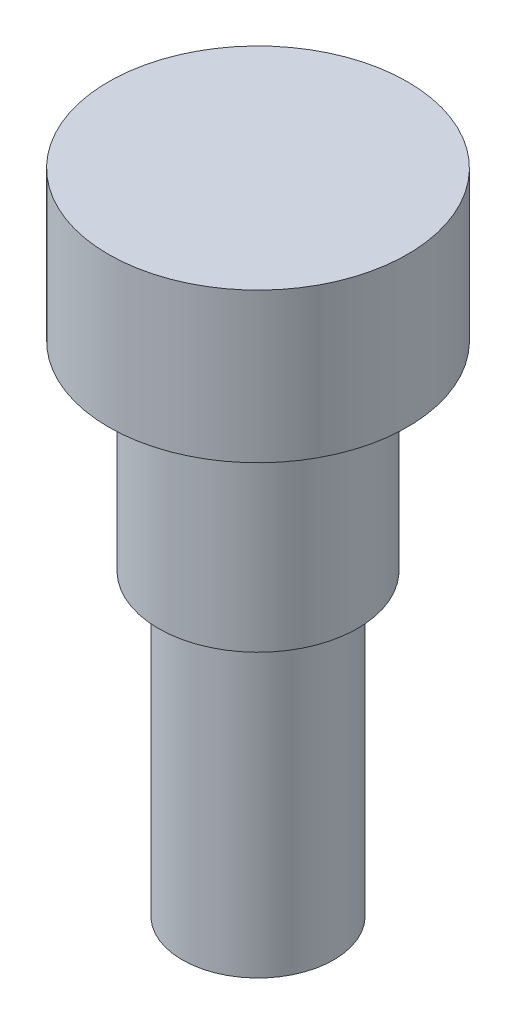
from build123d import *


with BuildPart() as part:
    # Sketch1 → Revolve1 (revolve)
    with BuildSketch(Plane.XY):
        Polygon((0, -9.525), (2.413, -9.525), (2.413, 0), (3.175, 0), (3.175, 6.35), (4.7625, 6.35), (4.7625, 11.1125), (0, 11.1125), align=None)
    revolve(axis=Axis((0, 32.639266451, 0), (0, -1, 0)))


solid = part.part
